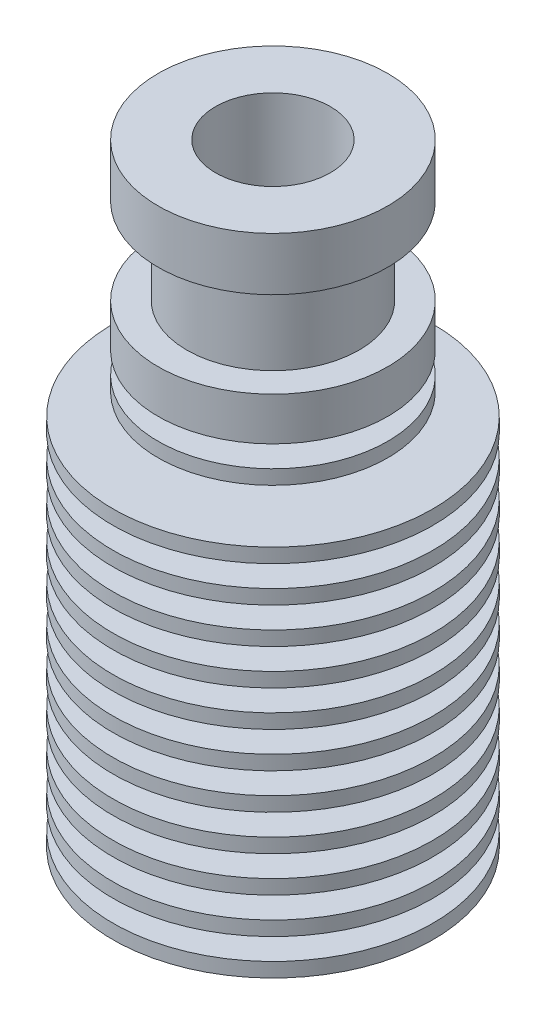
from build123d import *

# Parameters (mm, degrees)
SKETCH2_W           = 8.15
SKETCH2_H           = 1
LPATTERN1_COUNT     = 11
LPATTERN1_PITCH     = 2.5
SKETCH4_R           = 3.25
BOSS_EXTRUDE1_DEPTH = 2.1
SKETCH5_R           = 2.5
CUT_EXTRUDE1_DEPTH  = 2.1


with BuildPart() as part:
    # Sketch1 → Revolve1 (revolve)
    with BuildSketch(Plane.XY):
        Polygon((3, 0), (3, 15.1), (2.1, 15.730186784), (2.1, 34.869605677), (4, 36.2), (4, 42.7), (8, 42.7), (8, 39), (6, 39), (6, 33), (8, 33), (8, 30), (5.5, 30), (8, 0), align=None)
    revolve(axis=Axis((0, 0, 0), (0, 1, 0)))

    # Sketch2 → Revolve2 (revolve)
    with BuildSketch(Plane.XY):
        with Locations((7.075, 0.5)):
            Rectangle(SKETCH2_W, SKETCH2_H)
    revolve2 = revolve(axis=Axis((0, 0, 0), (0, 1, 0)))

    # LPattern1: Revolve2 ×11
    with Locations(*[(0, i * LPATTERN1_PITCH, 0) for i in range(1, LPATTERN1_COUNT)]):
        add(revolve2)

    # Sketch3 → Revolve3 (revolve)
    with BuildSketch(Plane.XY):
        Polygon((5.625, 28.5), (8, 28.5), (8, 27.5), (5.708333333, 27.5), align=None)
    revolve(axis=Axis((0, 0, 0), (0, -1, 0)))

    # Sketch4 → Boss-Extrude1 (add)
    with BuildSketch(Plane.XZ):
        Circle(SKETCH4_R)
    extrude(amount=BOSS_EXTRUDE1_DEPTH)

    # Sketch5 → Cut-Extrude1 (cut)
    with BuildSketch(Plane.XZ.offset(2.1)):
        Circle(SKETCH5_R)
    extrude(amount=-CUT_EXTRUDE1_DEPTH, mode=Mode.SUBTRACT)


solid = part.part
